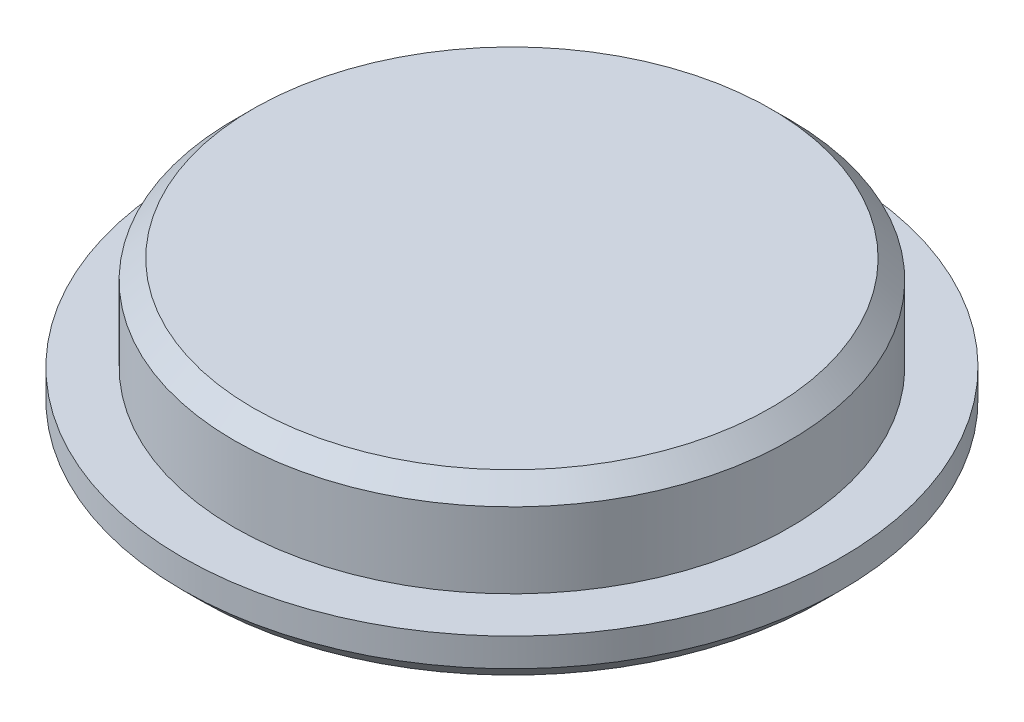
from build123d import *


with BuildPart() as part:
    # Sketch2 → Revolve1 (revolve)
    with BuildSketch(Plane.XY):
        Polygon((0, 0), (33, 0), (35, 2), (35, 5), (29.5, 5), (29.5, 13), (27.5, 15), (0, 15), align=None)
    revolve(axis=Axis((0, 0, 0), (0, -1, 0)))


solid = part.part
